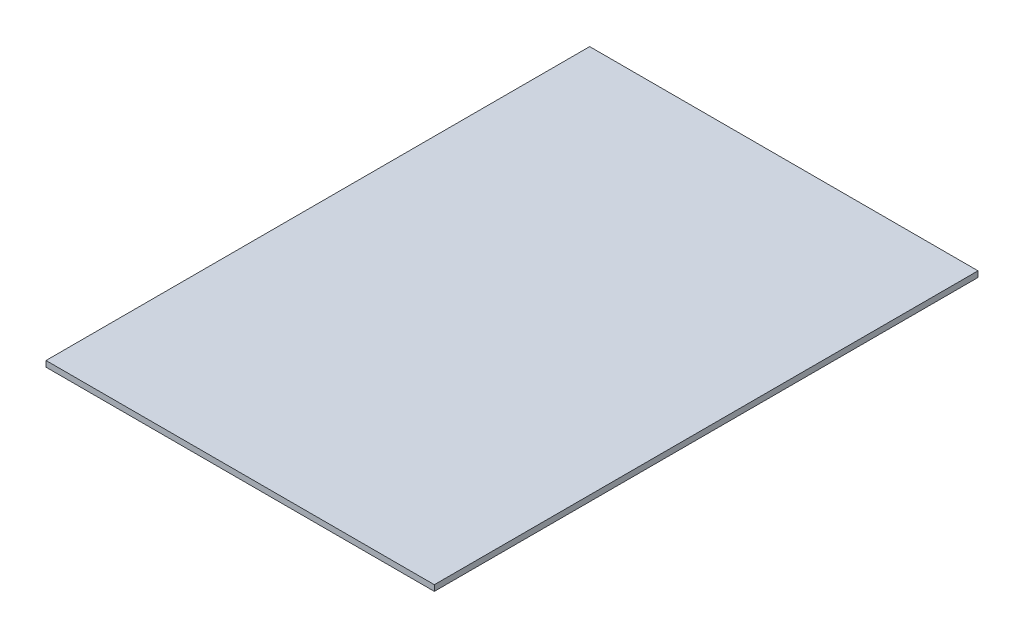
from build123d import *

# Parameters (mm, degrees)
ESQUISSE1_W      = 200
ESQUISSE1_H      = 280
EXTRUSION1_DEPTH = 3


with BuildPart() as part:
    # Esquisse1 → Extrusion1 (new body)
    with BuildSketch(Plane(origin=(0, 0, 0), x_dir=(1, 0, 0), z_dir=(0, 1, 0))):
        with Locations((100, 140)):
            Rectangle(ESQUISSE1_W, ESQUISSE1_H)
    extrude(amount=EXTRUSION1_DEPTH)


solid = part.part
